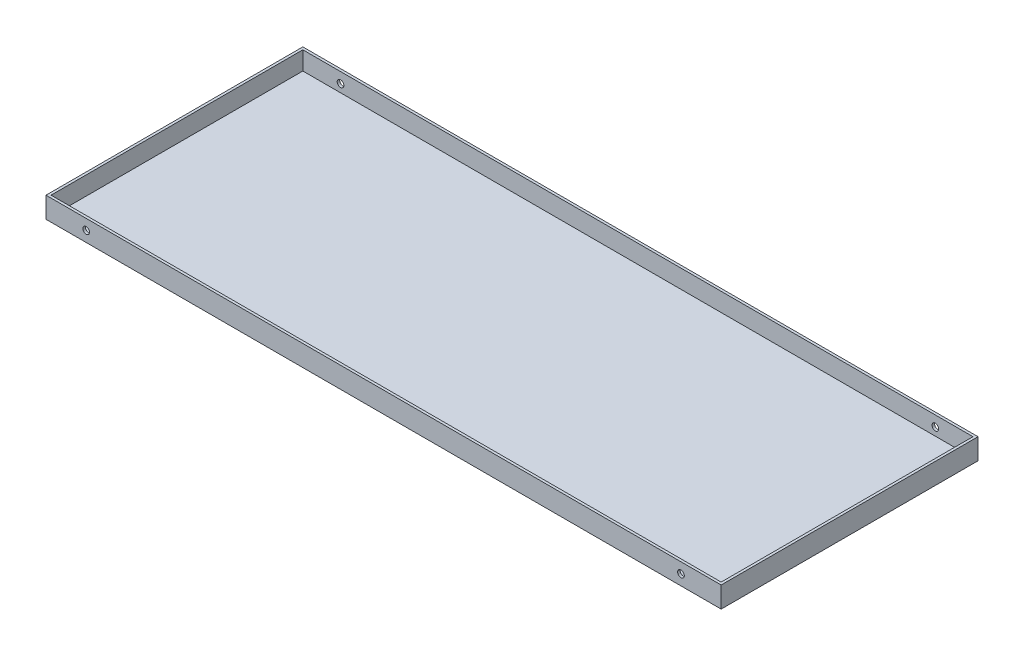
from build123d import *

# Parameters (mm, degrees)
SKETCH_2_W          = 807
SKETCH_2_H          = 307
EXTRUDE_1_DEPTH     = 25
SKETCH_3_W          = 801
SKETCH_3_H          = 301
CUT_EXTRUDE_1_DEPTH = 22
SKETCH_4_R          = 4
CUT_EXTRUDE_2_DEPTH = 308


with BuildPart() as part:
    # 草圖2 → 填料-伸長1 (new body)
    with BuildSketch(Plane(origin=(0, 0, 0), x_dir=(1, 0, 0), z_dir=(0, 1, 0))):
        with Locations((403.5, -153.5)):
            Rectangle(SKETCH_2_W, SKETCH_2_H)
    extrude(amount=EXTRUDE_1_DEPTH)

    # 草圖3 → 除料-伸長1 (cut)
    with BuildSketch(Plane(origin=(0, 25, 0), x_dir=(1, 0, 0), z_dir=(0, 1, 0))):
        with Locations((403.5, -153.5)):
            Rectangle(SKETCH_3_W, SKETCH_3_H)
    extrude(amount=-CUT_EXTRUDE_1_DEPTH, mode=Mode.SUBTRACT)

    # 草圖4 → 除料-伸長2 (cut, through all)
    with BuildSketch(Plane.XY.offset(307)):
        with Locations((759, 12.5)):
            Circle(SKETCH_4_R)
        with Locations((48, 12.5)):
            Circle(SKETCH_4_R)
    extrude(amount=-CUT_EXTRUDE_2_DEPTH, mode=Mode.SUBTRACT)


solid = part.part
